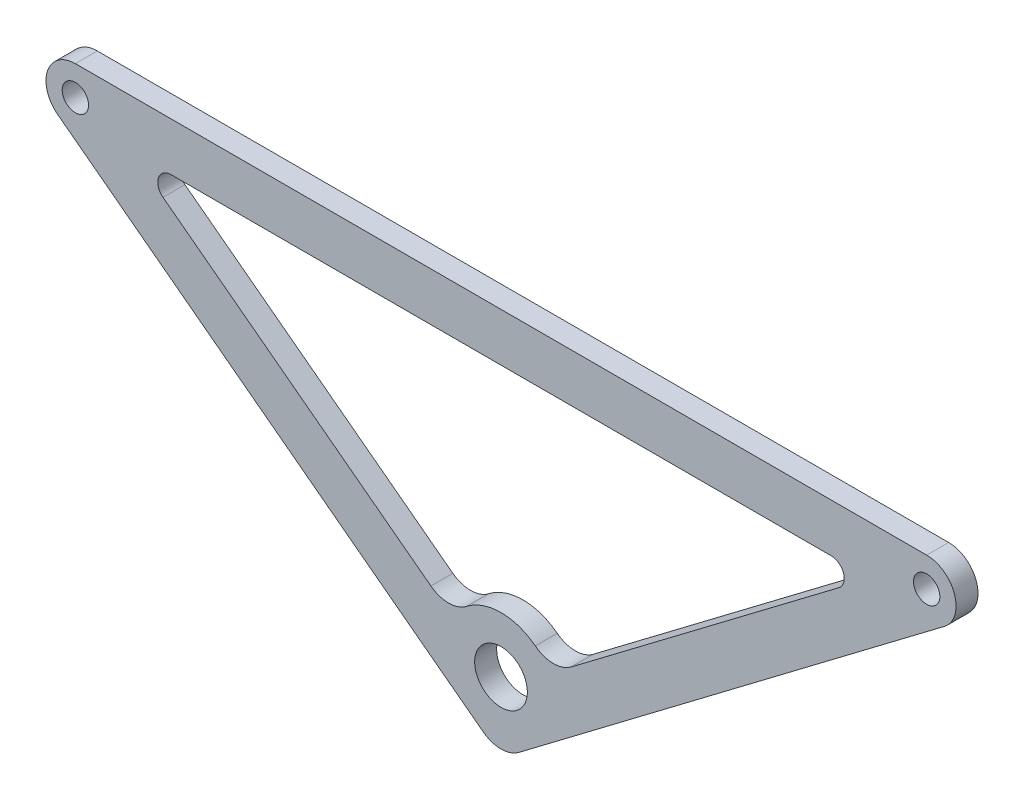
from build123d import *

# Parameters (mm, degrees)
SKETCH1_R           = 3
SKETCH1_R_2         = 6
BOSS_EXTRUDE1_DEPTH = 2.5


with BuildPart() as part:
    # Sketch1 → Boss-Extrude1 (new body, symmetric)
    with BuildSketch(Plane.XY):
        with BuildLine():
            Line((96.909065007, 0), (-96.909065007, 0))
            ThreePointArc((-96.909065007, 0), (-103.256738035, -4.565267366), (-100.94836092, -12.035609666))
            Line((-100.94836092, -12.035609666), (-4.039295913, -85.339986595))
            ThreePointArc((-4.039295913, -85.339986595), (0, -86.695623071), (4.039295913, -85.339986595))
            Line((4.039295913, -85.339986595), (100.94836092, -12.035609666))
            ThreePointArc((100.94836092, -12.035609666), (103.256738035, -4.565267366), (96.909065007, 0))
        make_face()
        with Locations((96.909065007, -6.695623071)):
            Circle(SKETCH1_R, mode=Mode.SUBTRACT)
        with Locations((-96.909065007, -6.695623071)):
            Circle(SKETCH1_R, mode=Mode.SUBTRACT)
        with Locations((0, -72.476809125)):
            Circle(SKETCH1_R_2, mode=Mode.SUBTRACT)
        with BuildLine():
            Line((-76.954542332, -16.392601796), (-15.971447816, -62.521699692))
            ThreePointArc((-15.971447816, -62.521699692), (-11.880304954, -63.878041653), (-7.809525514, -62.461754894))
            ThreePointArc((-7.809525514, -62.461754894), (0, -59.776809125), (7.809525514, -62.461754894))
            ThreePointArc((7.809525514, -62.461754894), (11.880304954, -63.878041653), (15.971447816, -62.521699692))
            Line((15.971447816, -62.521699692), (76.954542332, -16.392601796))
            ThreePointArc((76.954542332, -16.392601796), (77.988819691, -13.045485827), (75.144720063, -11))
            Line((75.144720063, -11), (-75.144720063, -11))
            ThreePointArc((-75.144720063, -11), (-77.988819691, -13.045485827), (-76.954542332, -16.392601796))
        make_face(mode=Mode.SUBTRACT)
    extrude(amount=BOSS_EXTRUDE1_DEPTH, both=True)


solid = part.part
